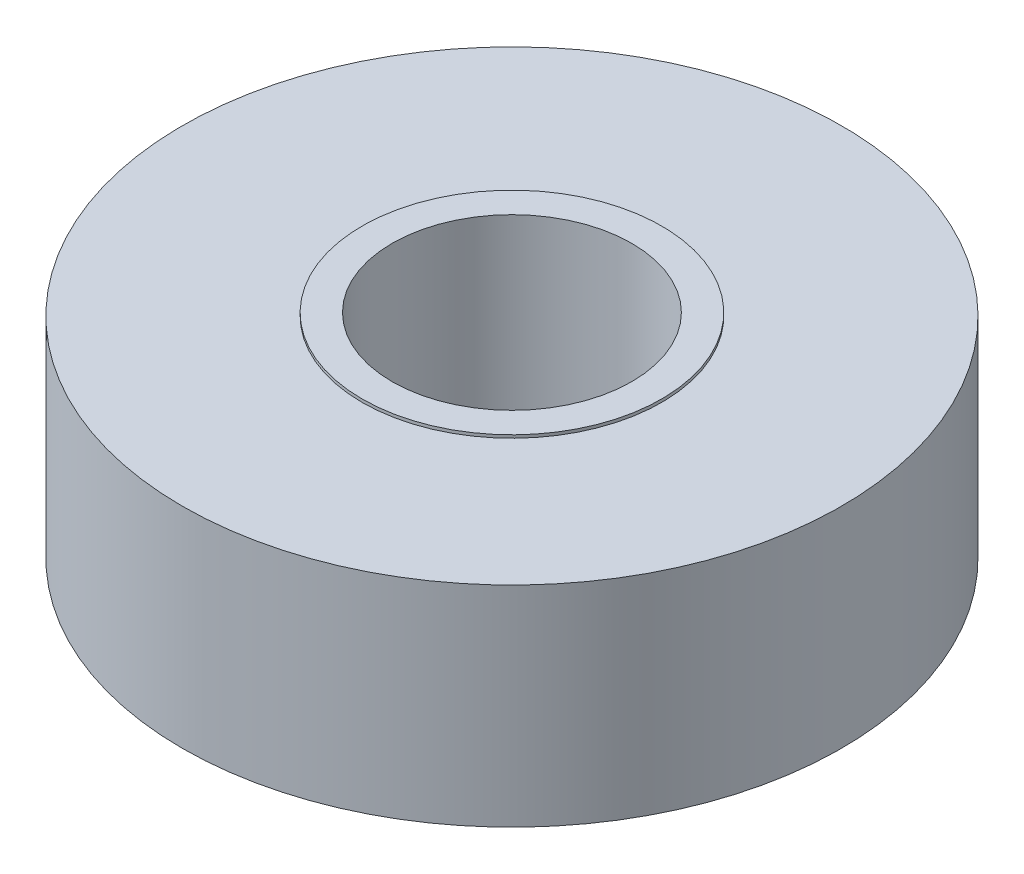
from build123d import *

# Parameters (mm, degrees)
CROQUIS1_R              = 11
CROQUIS1_R_2            = 4
SALIENTE_EXTRUIR1_DEPTH = 3.5
CROQUIS2_R              = 5
CROQUIS2_R_2            = 4
SALIENTE_EXTRUIR2_DEPTH = 3.6


with BuildPart() as part:
    # Croquis1 → Saliente-Extruir1 (new body, symmetric)
    with BuildSketch(Plane(origin=(0, 0, 0), x_dir=(1, 0, 0), z_dir=(0, 1, 0))):
        Circle(CROQUIS1_R)
        Circle(CROQUIS1_R_2, mode=Mode.SUBTRACT)
    extrude(amount=SALIENTE_EXTRUIR1_DEPTH, both=True)

    # Croquis2 → Saliente-Extruir2 (add, symmetric)
    with BuildSketch(Plane(origin=(0, 0, 0), x_dir=(1, 0, 0), z_dir=(0, 1, 0))):
        Circle(CROQUIS2_R)
        Circle(CROQUIS2_R_2, mode=Mode.SUBTRACT)
    extrude(amount=SALIENTE_EXTRUIR2_DEPTH, both=True)


solid = part.part
